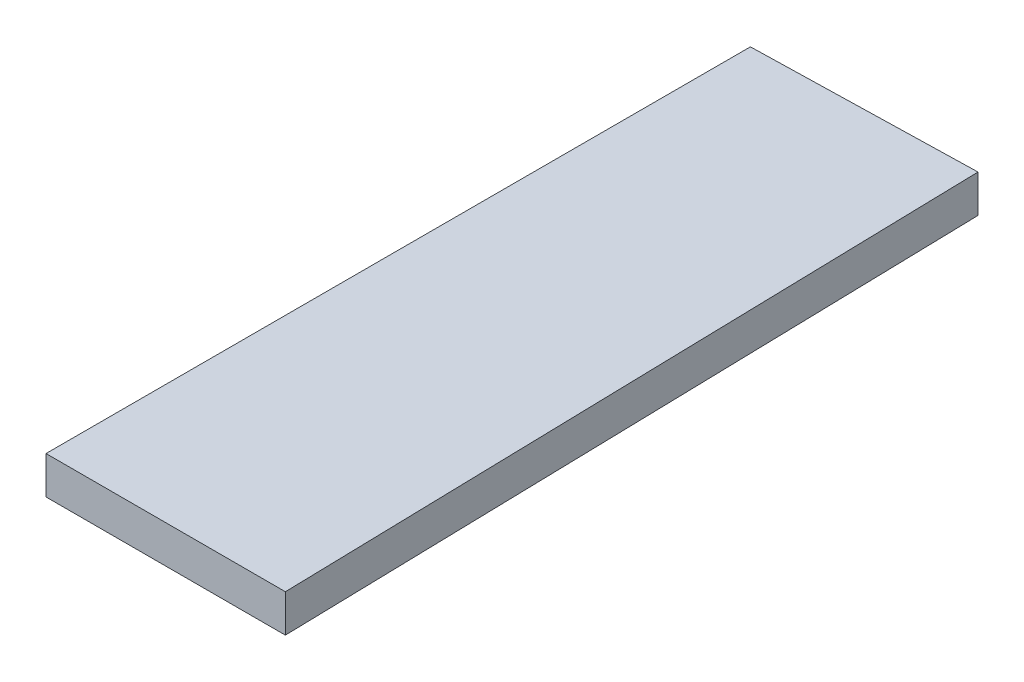
from build123d import *

# Parameters (mm, degrees)
BOSS_EXTRU_1_DEPTH = 2


with BuildPart() as part:
    # Esquisse1 → Boss.-Extru.1 (new body)
    with BuildSketch(Plane(origin=(0, 0, 0), x_dir=(1, 0, 0), z_dir=(0, 1, 0))):
        Polygon((0, 0), (12.723503216, -2.136e-05), (11.810481919, 37.725728292), (0, 37.439896423), align=None)
    extrude(amount=BOSS_EXTRU_1_DEPTH)


solid = part.part
